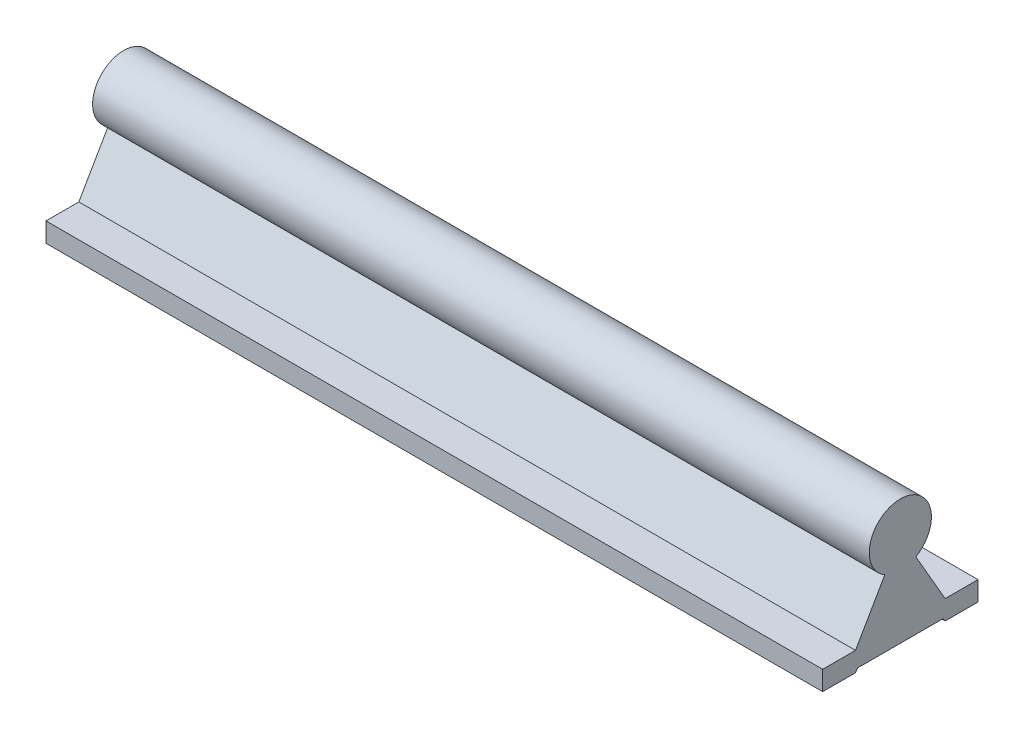
from build123d import *

# Parameters (mm, degrees)
BOSS_EXTRUDE1_DEPTH = 200


with BuildPart() as part:
    # Sketch1 → Boss-Extrude1 (new body)
    with BuildSketch(Plane(origin=(0, 0, 0), x_dir=(0, 0, -1), z_dir=(1, 0, 0))):
        with BuildLine():
            Line((-20, -25), (-20, -20))
            Line((-20, -20), (-11.547005384, -20))
            Line((-11.547005384, -20), (-4, -6.92820323))
            ThreePointArc((-4, -6.92820323), (0, 8), (4, -6.92820323))
            Line((4, -6.92820323), (11.547005384, -20))
            Line((11.547005384, -20), (20, -20))
            Line((20, -20), (20, -25))
            Line((20, -25), (11.547005384, -25))
            Line((11.547005384, -25), (10.997825762, -24.2))
            Line((10.997825762, -24.2), (-10.997825762, -24.2))
            Line((-10.997825762, -24.2), (-11.547005384, -25))
            Line((-11.547005384, -25), (-20, -25))
        make_face()
    extrude(amount=BOSS_EXTRUDE1_DEPTH)


solid = part.part
